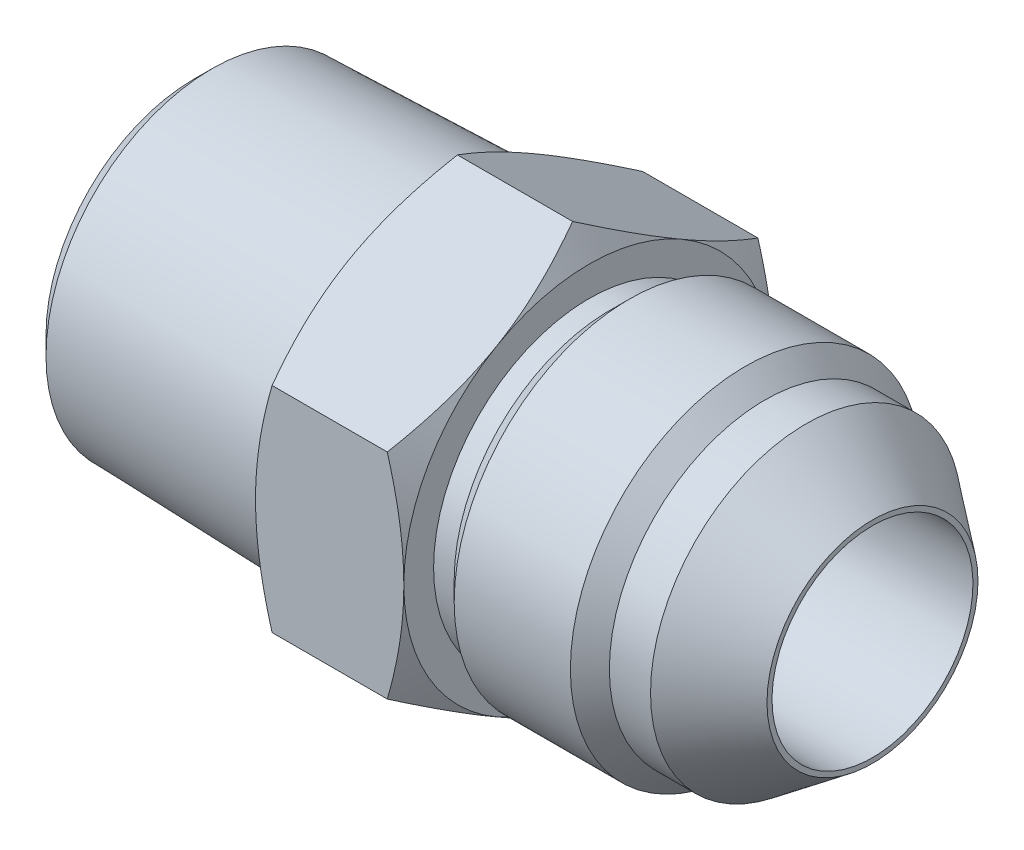
from build123d import *

# Parameters (mm, degrees)
SKETCH6_W           = 52.324
SKETCH6_H           = 13.49375
EXTRUDE1_DEPTH      = 11.43
SKETCH7_W           = 52.324
SKETCH7_H           = 7.747
SKETCH17_R          = 13.49375
CUT_EXTRUDE1_DEPTH  = 19.05
SKETCH19_R          = 13.335
BOSS_EXTRUDE1_DEPTH = 19.05
BOSS_EXTRUDE1_TAPER = 1.75
CHAMFER1_SIZE2      = 1.360714286
CHAMFER1_SIZE       = 1.404253042
SKETCH22_R          = 13.335
BOSS_EXTRUDE3_DEPTH = 19.05
BOSS_EXTRUDE3_TAPER = 15
SKETCH23_R          = 7.747
CUT_EXTRUDE2_DEPTH  = 19.05


with BuildPart() as part:
    # Sketch6 → Revolve3 (revolve)
    with BuildSketch(Plane.XY):
        with Locations((0, 6.746875)):
            Rectangle(SKETCH6_W, SKETCH6_H)
    revolve(axis=Axis((-26.162, 0, 0), (1, 0, 0)))

    # Sketch12 → Extrude1 (add)
    with BuildSketch(Plane(origin=(-7.112, 0, 0), x_dir=(0, 0, -1), z_dir=(1, 0, 0))):
        Polygon((0, 16.497783942), (-14.2875, 8.248891971), (-14.2875, -8.248891971), (0, -16.497783942), (14.2875, -8.248891971), (14.2875, 8.248891971), align=None)
    extrude(amount=EXTRUDE1_DEPTH)

    # Sketch10 → Cut-Revolve6 (revolve, cut)
    with BuildSketch(Plane.XY):
        Polygon((7.407315329, 13.49375), (4.318, 13.49375), (4.318, 11.991934671), (5.9055, 11.991934671), align=None)
        Polygon((26.162, 13.49375), (16.365996909, 13.49375), (17.867812238, 11.991934671), (21.042812238, 11.991934671), (26.162, 8.13435), align=None)
    revolve(axis=Axis((-26.162, 0, 0), (1, 0, 0)), mode=Mode.SUBTRACT)

    # Sketch7 → Cut-Revolve5 (revolve, cut)
    with BuildSketch(Plane.XY):
        with Locations((0, 3.8735)):
            Rectangle(SKETCH7_W, SKETCH7_H)
    revolve(axis=Axis((26.162, 0, 0), (-1, 0, 0)), mode=Mode.SUBTRACT)

    # Sketch13 → Cut-Revolve7 (revolve, cut)
    with BuildSketch(Plane.XY):
        Polygon((-7.112, 16.497783942), (-7.112, 14.2875), (-5.835891971, 16.497783942), align=None)
        Polygon((3.041891971, 16.497783942), (4.318, 14.2875), (4.318, 16.497783942), align=None)
    revolve(axis=Axis((-26.162, 0, 0), (1, 0, 0)), mode=Mode.SUBTRACT)

    # Sketch17 → Cut-Extrude1 (cut)
    with BuildSketch(Plane.ZY.offset(26.162)):
        Circle(SKETCH17_R)
    extrude(amount=-CUT_EXTRUDE1_DEPTH, mode=Mode.SUBTRACT)


with BuildPart() as body_2:
    # Sketch19 → Boss-Extrude1 (new body)
    with BuildSketch(Plane(origin=(-7.112, 0, 0), x_dir=(0, 0, -1), z_dir=(1, 0, 0))):
        Circle(SKETCH19_R)
    extrude(amount=-BOSS_EXTRUDE1_DEPTH, taper=BOSS_EXTRUDE1_TAPER)

    # Chamfer1
    chamfer1_edges = [body_2.edges().sort_by_distance(p)[0] for p in [
        (-26.162, 0, 12.752969859),
    ]]
    chamfer(chamfer1_edges, length=CHAMFER1_SIZE, length2=CHAMFER1_SIZE2)

    # Sketch22 → Boss-Extrude3 (add)
    with BuildSketch(Plane(origin=(-7.112, 0, 0), x_dir=(0, 0, -1), z_dir=(1, 0, 0))):
        Circle(SKETCH22_R)
    extrude(amount=-BOSS_EXTRUDE3_DEPTH, taper=BOSS_EXTRUDE3_TAPER)

    # Combine1: union part
    add(part.part)

    # Sketch23 → Cut-Extrude2 (cut)
    with BuildSketch(Plane.ZY.offset(26.162)):
        Circle(SKETCH23_R)
    extrude(amount=-CUT_EXTRUDE2_DEPTH, mode=Mode.SUBTRACT)


solid = body_2.part
